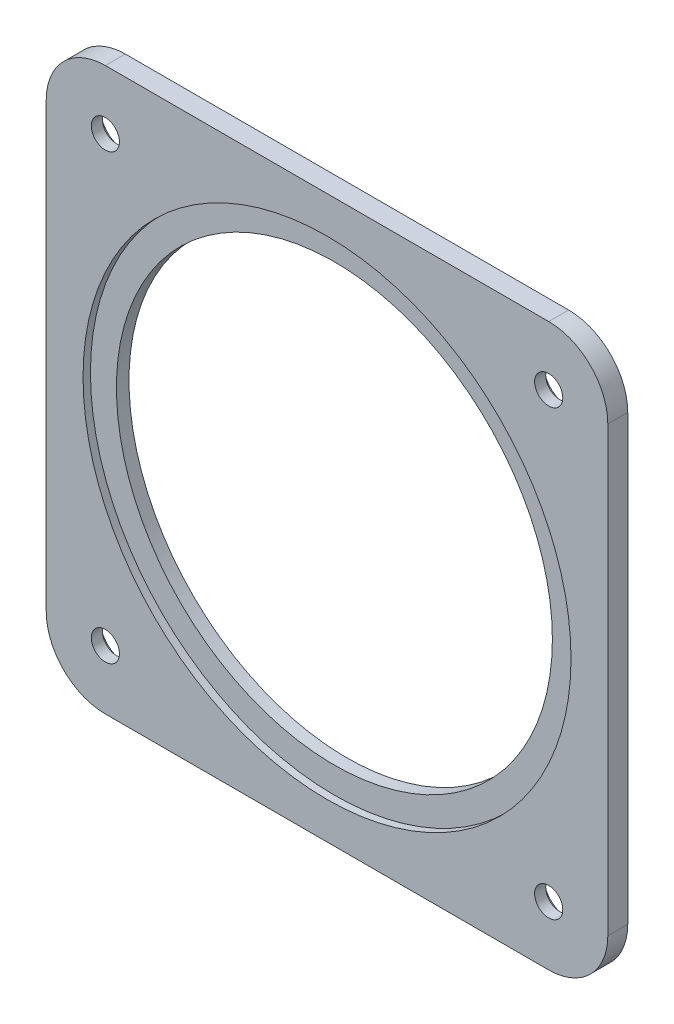
from build123d import *

# Parameters (mm, degrees)
SKETCH1_R           = 73.75
SKETCH1_R_2         = 4.7625
BOSS_EXTRUDE1_DEPTH = 6.75
SKETCH2_R           = 8.5
CUT_EXTRUDE1_DEPTH  = 3
SKETCH3_R           = 82.55
CUT_EXTRUDE2_DEPTH  = 2.5


with BuildPart() as part:
    # Sketch1 → Boss-Extrude1 (new body)
    with BuildSketch(Plane.XY):
        with BuildLine():
            Line((75, -95), (-75, -95))
            ThreePointArc((-75, -95), (-89.142135624, -89.142135624), (-95, -75))
            Line((-95, -75), (-95, 75))
            ThreePointArc((-95, 75), (-89.142135624, 89.142135624), (-75, 95))
            Line((-75, 95), (75, 95))
            ThreePointArc((75, 95), (89.142135624, 89.142135624), (95, 75))
            Line((95, 75), (95, -75))
            ThreePointArc((95, -75), (89.142135624, -89.142135624), (75, -95))
        make_face()
        Circle(SKETCH1_R, mode=Mode.SUBTRACT)
        with Locations((-75, 75)):
            Circle(SKETCH1_R_2, mode=Mode.SUBTRACT)
        with Locations((75, 75)):
            Circle(SKETCH1_R_2, mode=Mode.SUBTRACT)
        with Locations((75, -75)):
            Circle(SKETCH1_R_2, mode=Mode.SUBTRACT)
        with Locations((-75, -75)):
            Circle(SKETCH1_R_2, mode=Mode.SUBTRACT)
    extrude(amount=BOSS_EXTRUDE1_DEPTH)

    # Sketch2 → Cut-Extrude1 (cut)
    with BuildSketch(Plane(origin=(0, 0, 0), x_dir=(-1, 0, 0), z_dir=(0, 0, -1))):
        with Locations((-75, 75)):
            Circle(SKETCH2_R)
        with Locations((75, 75)):
            Circle(SKETCH2_R)
        with Locations((75, -75)):
            Circle(SKETCH2_R)
        with Locations((-75, -75)):
            Circle(SKETCH2_R)
    extrude(amount=-CUT_EXTRUDE1_DEPTH, mode=Mode.SUBTRACT)

    # Sketch3 → Cut-Extrude2 (cut)
    with BuildSketch(Plane.XY.offset(6.75)):
        Circle(SKETCH3_R)
    extrude(amount=-CUT_EXTRUDE2_DEPTH, mode=Mode.SUBTRACT)


solid = part.part
